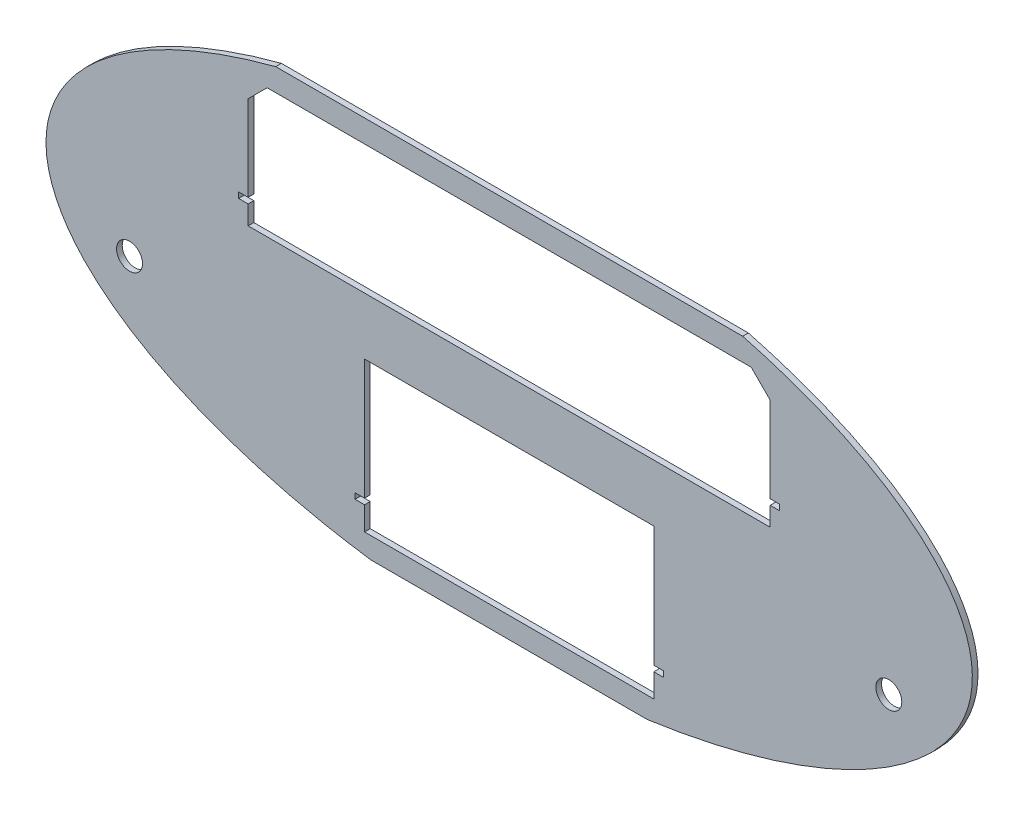
from build123d import *

# Parameters (mm, degrees)
SKETCH1_RX          = 244
SKETCH1_RY          = 110
BOSS_EXTRUDE1_DEPTH = 3
SKETCH12_R          = 6.83635542
CUT_EXTRUDE8_DEPTH  = 4
SKETCH13_W          = 488
SKETCH13_H          = 5
SKETCH13_H_2        = 15
CUT_EXTRUDE9_DEPTH  = 4
CUT_EXTRUDE10_DEPTH = 10
CUT_EXTRUDE11_DEPTH = 10
CHAMFER1_SIZE       = 10


with BuildPart() as part:
    # Sketch1 → Boss-Extrude1 (new body)
    with BuildSketch(Plane.XY):
        with Locations((0, 0)):
            Ellipse(SKETCH1_RX, SKETCH1_RY)
    extrude(amount=-BOSS_EXTRUDE1_DEPTH)

    # Sketch12 → Cut-Extrude8 (cut, through all)
    with BuildSketch(Plane.XY):
        with Locations((200, -30)):
            Circle(SKETCH12_R)
        with Locations((-200, -30)):
            Circle(SKETCH12_R)
    extrude(amount=-CUT_EXTRUDE8_DEPTH, mode=Mode.SUBTRACT)

    # Sketch13 → Cut-Extrude9 (cut, through all)
    with BuildSketch(Plane.XY):
        with Locations((0, -107.5)):
            Rectangle(SKETCH13_W, SKETCH13_H)
        with Locations((0, 102.5)):
            Rectangle(SKETCH13_W, SKETCH13_H_2)
    extrude(amount=-CUT_EXTRUDE9_DEPTH, mode=Mode.SUBTRACT)

    # Sketch14 → Cut-Extrude10 (cut)
    with BuildSketch(Plane.XY):
        Polygon((-76.2, -81.5), (-76.2, -93.9), (76.2, -93.9), (76.2, -81.5), (81.2, -81.5), (81.2, -78.5), (76.2, -78.5), (76.2, -15), (-76.2, -15), (-76.2, -78.5), (-81.2, -78.5), (-81.2, -81.5), align=None)
    extrude(amount=-CUT_EXTRUDE10_DEPTH, mode=Mode.SUBTRACT)

    # Sketch15 → Cut-Extrude11 (cut)
    with BuildSketch(Plane.XY):
        Polygon((-137.5, 83.1), (137.5, 83.1), (137.5, 28.1), (142.5, 28.1), (142.5, 25.1), (137.5, 25.1), (137.5, 15.1), (-137.5, 15.1), (-137.5, 25.1), (-142.5, 25.1), (-142.5, 28.1), (-137.5, 28.1), align=None)
    extrude(amount=-CUT_EXTRUDE11_DEPTH, mode=Mode.SUBTRACT)

    # Chamfer1
    chamfer1_edges = [part.edges().sort_by_distance(p)[0] for p in [
        (-137.5, 83.1, -1.5),
        (137.5, 83.1, -1.5),
    ]]
    chamfer(chamfer1_edges, length=CHAMFER1_SIZE)


solid = part.part
